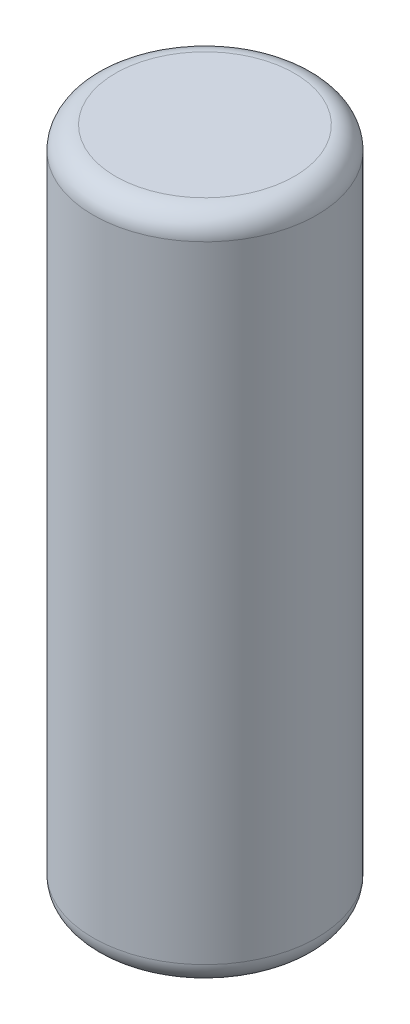
from build123d import *

# Parameters (mm, degrees)
MAIN_PARACHUTE_BAG_PROFILE_R  = 63.5
MAIN_PARACHUTE_BAG_BODY_DEPTH = 381
FILLET1_R                     = 12.7


with BuildPart() as part:
    # Main Parachute Bag Profile → Main Parachute Bag Body (new body)
    with BuildSketch(Plane(origin=(0, 0, 0), x_dir=(1, 0, 0), z_dir=(0, 1, 0))):
        Circle(MAIN_PARACHUTE_BAG_PROFILE_R)
    extrude(amount=MAIN_PARACHUTE_BAG_BODY_DEPTH)

    # Fillet1
    fillet1_edges = [part.edges().sort_by_distance(p)[0] for p in [
        (-63.5, 0, 0),
        (-63.5, 381, 0),
    ]]
    fillet(fillet1_edges, radius=FILLET1_R)


solid = part.part
